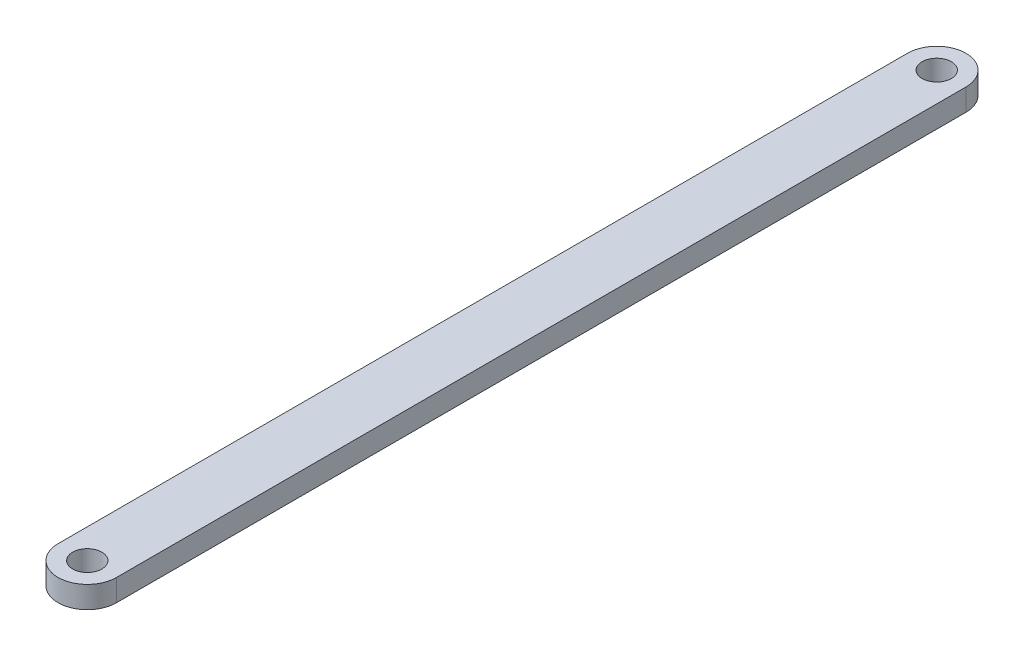
from build123d import *

# Parameters (mm, degrees)
SKETCH1_R           = 2
BOSS_EXTRUDE1_DEPTH = 3


with BuildPart() as part:
    # Sketch1 → Boss-Extrude1 (new body)
    with BuildSketch(Plane(origin=(0, 0, 0), x_dir=(1, 0, 0), z_dir=(0, 1, 0))):
        with BuildLine():
            Line((4, 58.125), (4, -58.125))
            ThreePointArc((4, -58.125), (0, -62.125), (-4, -58.125))
            Line((-4, -58.125), (-4, 58.125))
            ThreePointArc((-4, 58.125), (0, 62.125), (4, 58.125))
        make_face()
        with Locations((0, 58.125)):
            Circle(SKETCH1_R, mode=Mode.SUBTRACT)
        with Locations((0, -58.125)):
            Circle(SKETCH1_R, mode=Mode.SUBTRACT)
    extrude(amount=BOSS_EXTRUDE1_DEPTH)


solid = part.part
